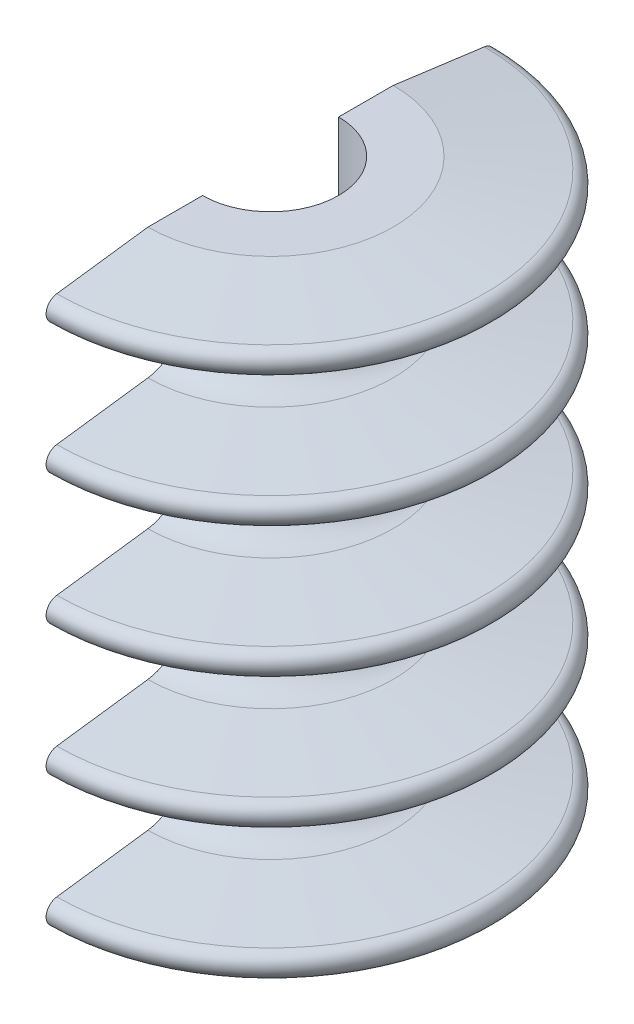
from build123d import *

# Parameters (mm, degrees)
SKETCH3_W          = 63.794129447
SKETCH3_H          = 110.135148007
CUT_EXTRUDE1_DEPTH = 94
SKETCH4_R          = 1.7
CUT_EXTRUDE2_DEPTH = 37.951032893
SKETCH5_R          = 2.95
CUT_EXTRUDE3_DEPTH = 3.8


with BuildPart() as part:
    # Sketch2 → Revolve1 (revolve)
    with BuildSketch(Plane.XY):
        with BuildLine():
            Line((-20.2, -39), (-35.2, -41))
            ThreePointArc((-35.2, -41), (-36.951032793, -43), (-35.2, -45))
            Line((-35.2, -45), (-20.2, -47))
            Line((-20.2, -47), (-11.2, -47))
            Line((-11.2, -47), (-11.2, 47))
            Line((-11.2, 47), (-20.2, 47))
            Line((-20.2, 47), (-35.2, 45))
            ThreePointArc((-35.2, 45), (-36.951032793, 43), (-35.2, 41))
            Line((-35.2, 41), (-20.2, 39))
            ThreePointArc((-20.2, 39), (-14.290264322, 32.25), (-20.2, 25.5))
            Line((-20.2, 25.5), (-35.2, 23.5))
            ThreePointArc((-35.2, 23.5), (-36.951032793, 21.5), (-35.2, 19.5))
            Line((-35.2, 19.5), (-20.2, 17.5))
            ThreePointArc((-20.2, 17.5), (-14.290264322, 10.75), (-20.2, 4))
            Line((-20.2, 4), (-35.2, 2))
            ThreePointArc((-35.2, 2), (-36.951032793, 0), (-35.2, -2))
            Line((-35.2, -2), (-20.2, -4))
            ThreePointArc((-20.2, -4), (-14.290264322, -10.75), (-20.2, -17.5))
            Line((-20.2, -17.5), (-35.2, -19.5))
            ThreePointArc((-35.2, -19.5), (-36.951032793, -21.5), (-35.2, -23.5))
            Line((-35.2, -23.5), (-20.2, -25.5))
            ThreePointArc((-20.2, -25.5), (-14.290264322, -32.25), (-20.2, -39))
        make_face()
    revolve(axis=Axis((0, 47, 0), (0, -1, 0)))

    # Sketch3 → Cut-Extrude1 (cut)
    with BuildSketch(Plane.XZ.offset(47)):
        with Locations((-31.897064724, -0.067055114)):
            Rectangle(SKETCH3_W, SKETCH3_H)
    extrude(amount=-CUT_EXTRUDE1_DEPTH, mode=Mode.SUBTRACT)

    # Sketch4 → Cut-Extrude2 (cut, through all)
    with BuildSketch(Plane(origin=(0, 0, 0), x_dir=(0, 0, -1), z_dir=(1, 0, 0))):
        with Locations((0, -32.25)):
            Circle(SKETCH4_R)
        with Locations((0, 32.25)):
            Circle(SKETCH4_R)
    extrude(amount=CUT_EXTRUDE2_DEPTH, mode=Mode.SUBTRACT)

    # Sketch5 → Cut-Extrude3 (cut)
    with BuildSketch(Plane(origin=(17, 0, 0), x_dir=(0, 0, -1), z_dir=(1, 0, 0))):
        with Locations((0, -32.25)):
            Circle(SKETCH5_R)
        with Locations((0, 32.25)):
            Circle(SKETCH5_R)
    extrude(amount=-CUT_EXTRUDE3_DEPTH, mode=Mode.SUBTRACT)


solid = part.part
